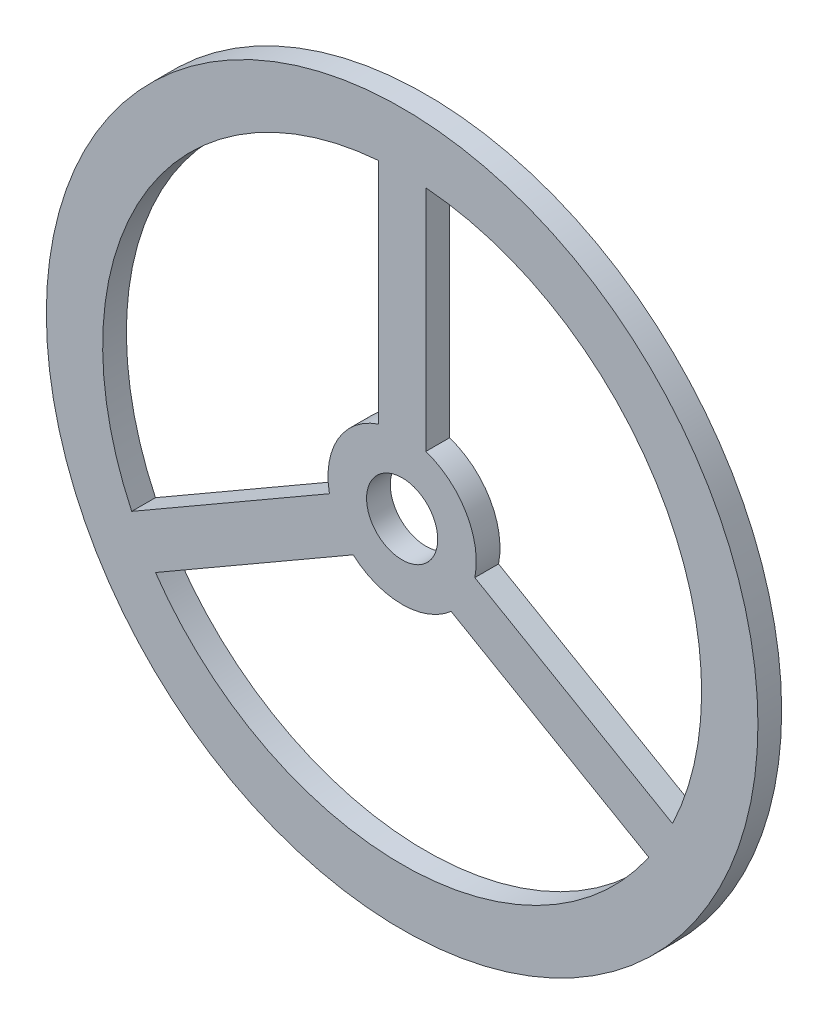
from build123d import *

# Parameters (mm, degrees)
SKETCH_1_R      = 60
SKETCH_1_R_2    = 6
EXTRUDE_1_DEPTH = 4


with BuildPart() as part:
    # 草图1 → 凸台-拉伸1 (new body)
    with BuildSketch(Plane.XY):
        Circle(SKETCH_1_R)
        Circle(SKETCH_1_R_2, mode=Mode.SUBTRACT)
        with BuildLine():
            Line((-4, 11.842719282), (-4, 50.341334905))
            ThreePointArc((-4, 50.341334905), (-43.734282891, 25.25), (-45.596874888, -21.706565837))
            Line((-45.596874888, -21.706565837), (-12.256095748, -2.457258026))
            ThreePointArc((-12.256095748, -2.457258026), (-10.825317547, 6.25), (-4, 11.842719282))
        make_face(mode=Mode.SUBTRACT)
        with BuildLine():
            Line((4, 11.842719282), (4, 50.341334905))
            ThreePointArc((4, 50.341334905), (43.734282891, 25.25), (45.596874888, -21.706565837))
            Line((45.596874888, -21.706565837), (12.256095748, -2.457258026))
            ThreePointArc((12.256095748, -2.457258026), (10.825317547, 6.25), (4, 11.842719282))
        make_face(mode=Mode.SUBTRACT)
        with BuildLine():
            Line((8.256095748, -9.385461256), (41.596874888, -28.634769068))
            ThreePointArc((41.596874888, -28.634769068), (0, -50.5), (-41.596874888, -28.634769068))
            Line((-41.596874888, -28.634769068), (-8.256095748, -9.385461256))
            ThreePointArc((-8.256095748, -9.385461256), (0, -12.5), (8.256095748, -9.385461256))
        make_face(mode=Mode.SUBTRACT)
    extrude(amount=EXTRUDE_1_DEPTH)


solid = part.part
